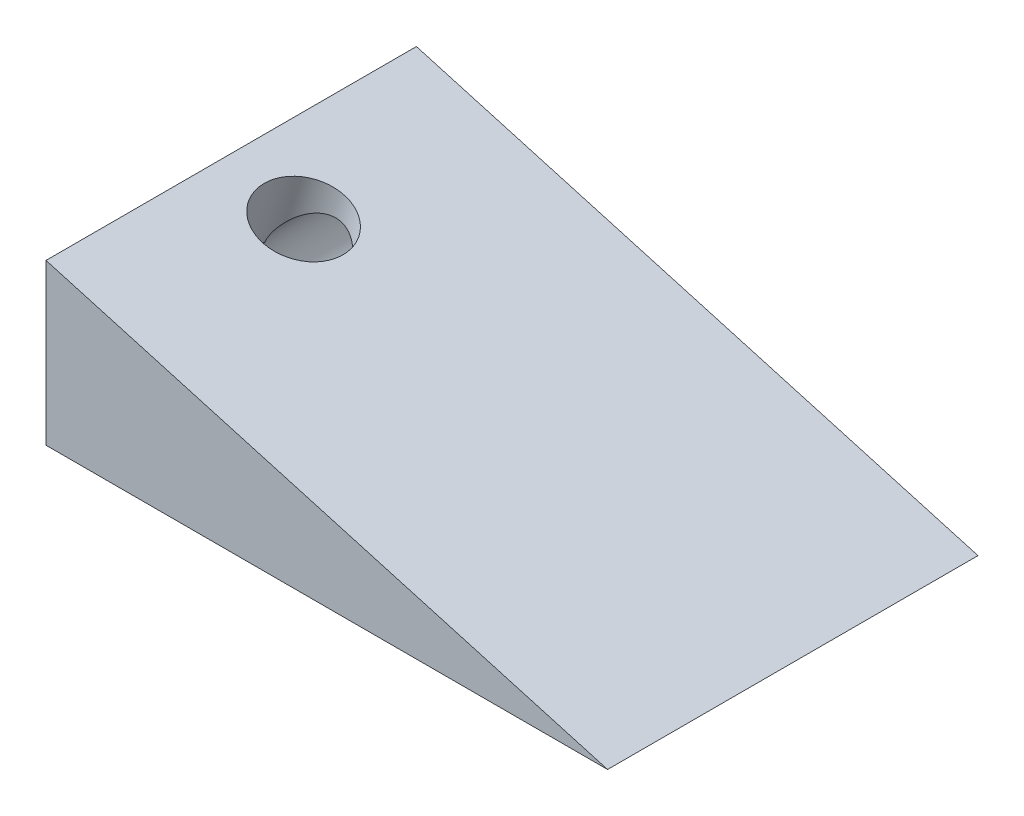
from build123d import *

# Parameters (mm, degrees)
BOSS_EXTRUDE1_DEPTH = 70
SKETCH4_R           = 7.747265665
CUT_EXTRUDE1_DEPTH  = 13
SKETCH7_R           = 8.715693707
CUT_EXTRUDE2_DEPTH  = 40


with BuildPart() as part:
    # Sketch1 → Boss-Extrude1 (new body)
    with BuildSketch(Plane.XY):
        Polygon((-44.780066958, 0), (61.341290068, 0), (-44.780066958, 30.254301436), align=None)
    extrude(amount=BOSS_EXTRUDE1_DEPTH)

    # Sketch4 → Cut-Extrude1 (cut)
    with BuildSketch(Plane(origin=(4.610887587, 16.173357987, 0), x_dir=(0.961681983, -0.274167401, 0), z_dir=(0.274167401, 0.961681983, 0))):
        with Locations((-37.136646247, -35)):
            Circle(SKETCH4_R)
    extrude(amount=-CUT_EXTRUDE1_DEPTH, mode=Mode.SUBTRACT)

    # Sketch7 → Cut-Extrude2 (cut)
    with BuildSketch(Plane(origin=(0, 0, 0), x_dir=(-1, 0, 0), z_dir=(0, 0, -1))):
        with Locations((33.204170233, 13.141177122)):
            Circle(SKETCH7_R)
    extrude(amount=-CUT_EXTRUDE2_DEPTH, mode=Mode.SUBTRACT)


solid = part.part
